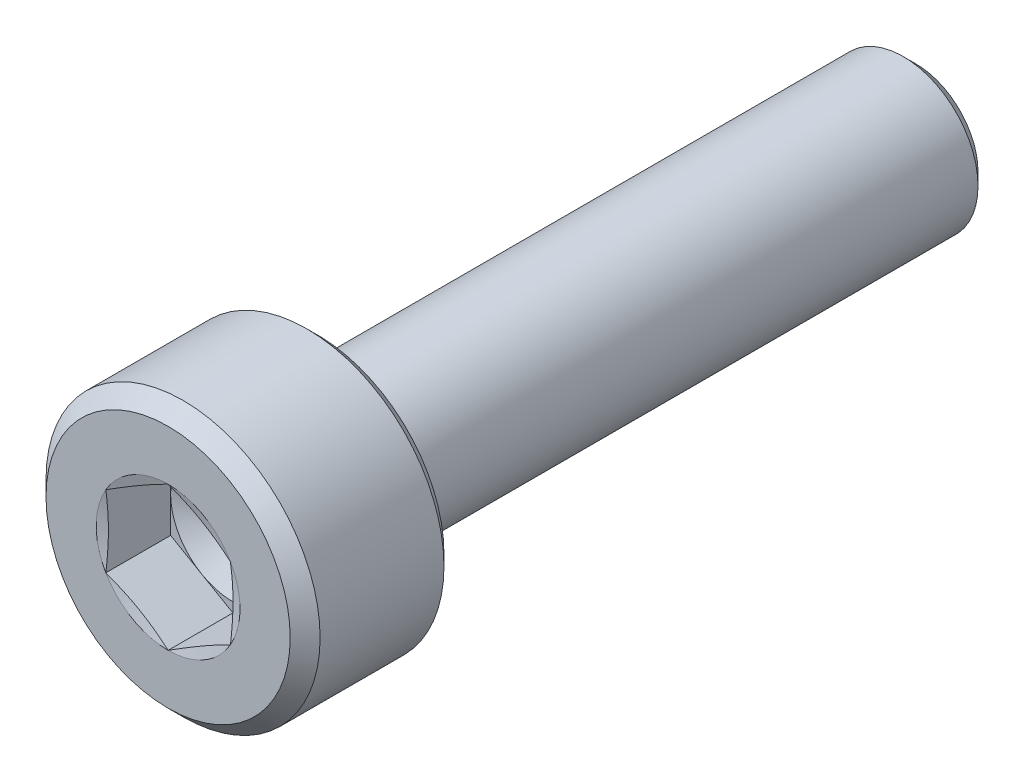
from build123d import *

# Parameters (mm, degrees)
CUT_EXTRUDE1_DEPTH = 1.3


with BuildPart() as part:
    # Sketch1 → Revolve1 (revolve)
    with BuildSketch(Plane(origin=(0, 0, 0), x_dir=(0, 0, -1), z_dir=(1, 0, 0))):
        with BuildLine():
            Line((0, 0), (0, 2.45))
            Line((0, 2.45), (0.3, 2.75))
            Line((0.3, 2.75), (2.785, 2.75))
            Line((2.785, 2.75), (3, 2.535))
            Line((3, 2.535), (3, 1.8))
            ThreePointArc((3, 1.8), (3.015193643, 1.74701055), (3.056157637, 1.710123155))
            Line((3.056157637, 1.710123155), (3.466157637, 1.510123155))
            ThreePointArc((3.466157637, 1.510123155), (3.48750205, 1.50256365), (3.51, 1.5))
            Line((3.51, 1.5), (14.75, 1.5))
            Line((14.75, 1.5), (15, 1.25))
            Line((15, 1.25), (15, 0))
            Line((15, 0), (0, 0))
        make_face()
    revolve(axis=Axis((0, 0, 0), (0, 0, -1)))

    # Sketch2 → Cut-Extrude1 (cut)
    with BuildSketch(Plane.XY):
        Polygon((0, 1.443375673), (-1.25, 0.721687836), (-1.25, -0.721687836), (0, -1.443375673), (1.25, -0.721687836), (1.25, 0.721687836), align=None)
    extrude(amount=-CUT_EXTRUDE1_DEPTH, mode=Mode.SUBTRACT)

    # Sketch3 → Cut-Revolve2 (revolve, cut)
    with BuildSketch(Plane(origin=(0, 0, 0), x_dir=(0, 0, -1), z_dir=(1, 0, 0))):
        Polygon((1.3, 0), (1.3, 1.25), (2.021687836, 0), align=None)
    revolve(axis=Axis((0, 0, -1.3), (0, 0, -1)), mode=Mode.SUBTRACT)

    # Sketch4 → Cut-Revolve3 (revolve, cut)
    with BuildSketch(Plane(origin=(0, 0, 0), x_dir=(0, 0, -1), z_dir=(1, 0, 0))):
        Polygon((0, 1.443375673), (0, 1.25), (0.051814855, 1.25), align=None)
    revolve(axis=Axis((0, 0, 0), (0, 0, -1)), mode=Mode.SUBTRACT)


solid = part.part
